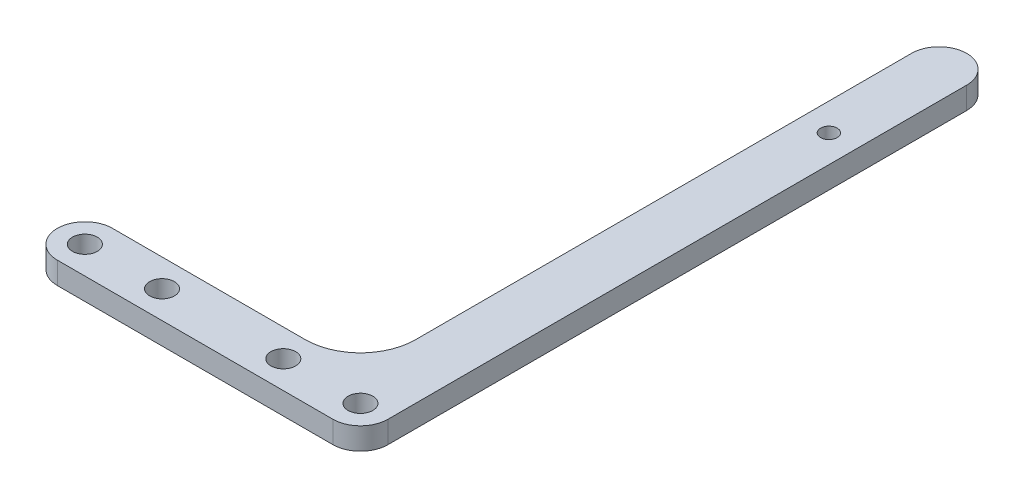
from build123d import *

# Parameters (mm, degrees)
SKETCH1_R           = 1.5
BOSS_EXTRUDE1_DEPTH = 4
SKETCH2_R           = 2.25
BOSS_EXTRUDE2_DEPTH = 4
FILLET1_R           = 10
FILLET2_R           = 5


with BuildPart() as part:
    # Sketch1 → Boss-Extrude1 (new body)
    with BuildSketch(Plane(origin=(0, 0, 0), x_dir=(1, 0, 0), z_dir=(0, 1, 0))):
        with BuildLine():
            Line((0, 0), (0, 100))
            ThreePointArc((0, 100), (5, 105), (10, 100))
            Line((10, 100), (10, 0))
            Line((10, 0), (0, 0))
        make_face()
        with Locations((5, 80)):
            Circle(SKETCH1_R, mode=Mode.SUBTRACT)
    extrude(amount=BOSS_EXTRUDE1_DEPTH)

    # Sketch2 → Boss-Extrude2 (add)
    with BuildSketch(Plane(origin=(0, 4, 0), x_dir=(1, 0, 0), z_dir=(0, 1, 0))):
        with BuildLine():
            Line((10, 0), (0, 0))
            Line((0, 0), (-45, 0))
            ThreePointArc((-45, 0), (-50, -5), (-45, -10))
            Line((-45, -10), (10, -10))
            Line((10, -10), (10, 0))
        make_face()
        with Locations((-45, -5)):
            Circle(SKETCH2_R, mode=Mode.SUBTRACT)
        with Locations((-31, -5)):
            Circle(SKETCH2_R, mode=Mode.SUBTRACT)
        with Locations((-9, -5)):
            Circle(SKETCH2_R, mode=Mode.SUBTRACT)
        with Locations((5, -5)):
            Circle(SKETCH2_R, mode=Mode.SUBTRACT)
    extrude(amount=-BOSS_EXTRUDE2_DEPTH)

    # Fillet1
    fillet1_edges = [part.edges().sort_by_distance(p)[0] for p in [
        (0, 2, 0),
    ]]
    fillet(fillet1_edges, radius=FILLET1_R)

    # Fillet2
    fillet2_edges = [part.edges().sort_by_distance(p)[0] for p in [
        (10, 2, 10),
    ]]
    fillet(fillet2_edges, radius=FILLET2_R)


solid = part.part
